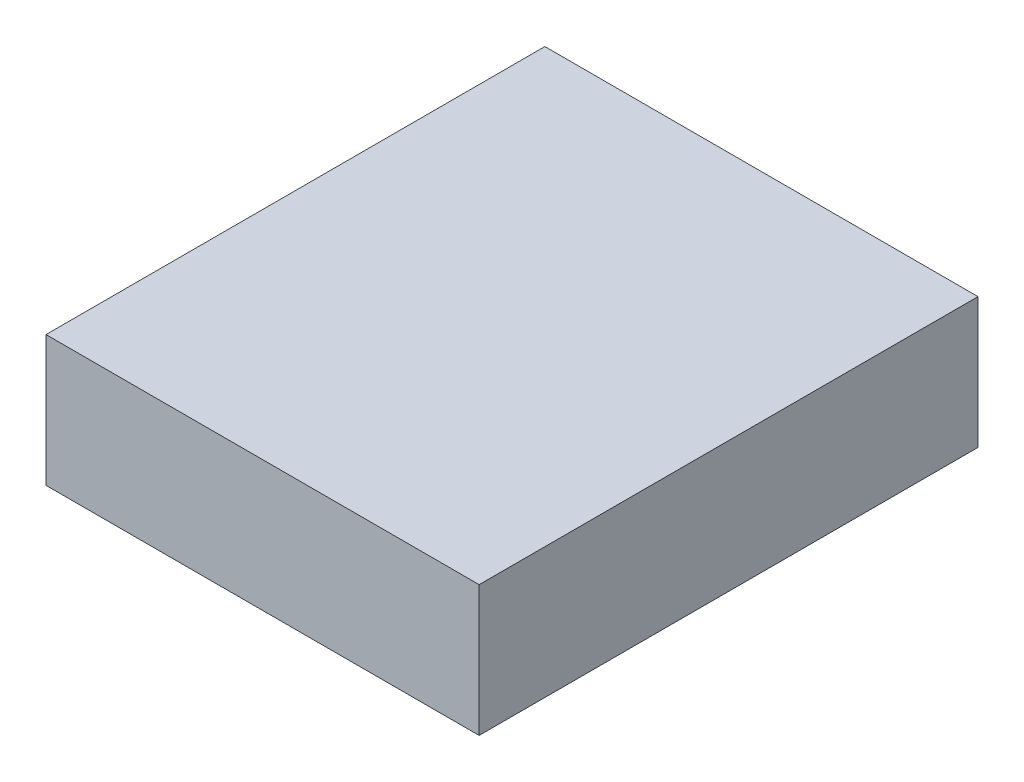
from build123d import *

# Parameters (mm, degrees)
SKETCH1_W           = 65.278
SKETCH1_H           = 75.184
BOSS_EXTRUDE1_DEPTH = 19.685
SKETCH3_R           = 2.54
BOSS_EXTRUDE2_DEPTH = 3.302


with BuildPart() as part:
    # Sketch1 → Boss-Extrude1 (new body)
    with BuildSketch(Plane(origin=(0, 0, 0), x_dir=(1, 0, 0), z_dir=(0, 1, 0))):
        with Locations((32.639, 37.592)):
            Rectangle(SKETCH1_W, SKETCH1_H)
    extrude(amount=BOSS_EXTRUDE1_DEPTH)

    # Sketch3 → Boss-Extrude2 (add)
    with BuildSketch(Plane.XZ):
        with Locations((16.51, -6.604)):
            Circle(SKETCH3_R)
    extrude(amount=BOSS_EXTRUDE2_DEPTH)


solid = part.part
